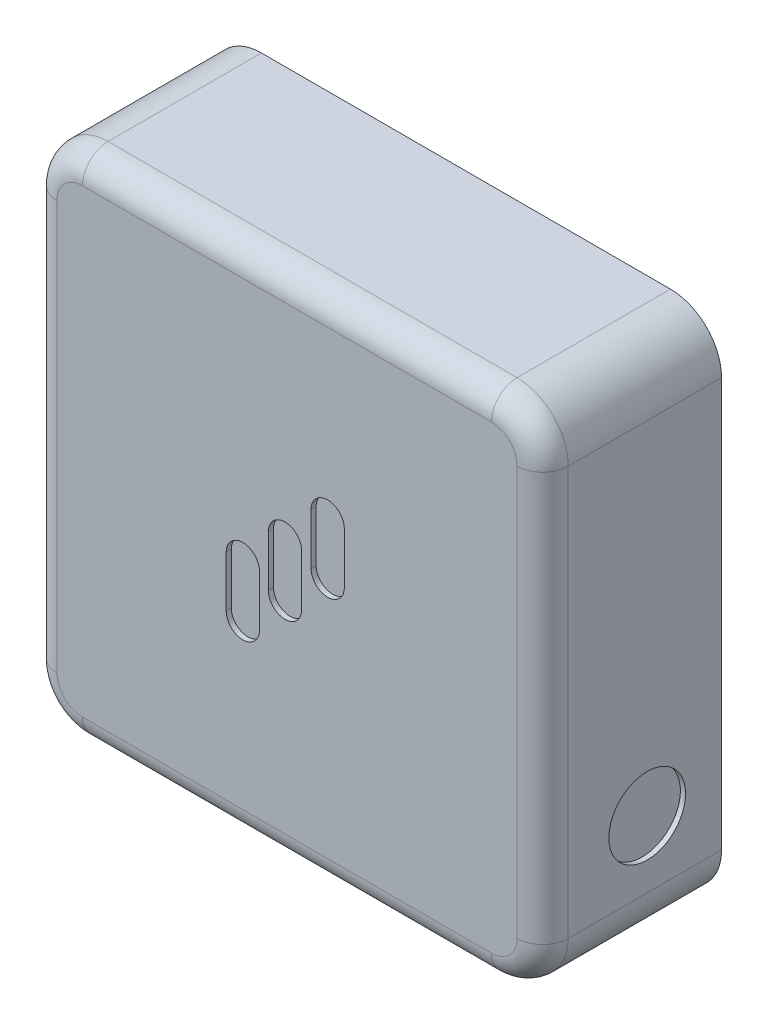
from build123d import *

# Parameters (mm, degrees)
SKETCH1_W           = 100
SKETCH1_H           = 100
BOSS_EXTRUDE2_DEPTH = 35
FILLET3_R           = 10
FILLET4_R           = 5
SKETCH2_R           = 7.5
CUT_EXTRUDE1_DEPTH  = 1
CUT_EXTRUDE2_DEPTH  = 1


with BuildPart() as part:
    # Sketch1 → Boss-Extrude2 (new body)
    with BuildSketch(Plane.XY):
        with Locations((-7.378614961, -23.844584937)):
            Rectangle(SKETCH1_W, SKETCH1_H)
    extrude(amount=BOSS_EXTRUDE2_DEPTH)

    # Fillet3
    fillet3_edges = [part.edges().sort_by_distance(p)[0] for p in [
        (-57.378614961, 26.155415063, 17.5),
        (42.621385039, 26.155415063, 17.5),
        (42.621385039, -73.844584937, 17.5),
        (-57.378614961, -73.844584937, 17.5),
    ]]
    fillet(fillet3_edges, radius=FILLET3_R)

    # Fillet4
    fillet4_edges = [part.edges().sort_by_distance(p)[0] for p in [
        (42.621385039, -23.844584937, 35),
        (-7.378614961, -73.844584937, 35),
        (-57.378614961, -23.844584937, 35),
        (-7.378614961, 26.155415063, 35),
        (39.692452851, 23.226482875, 35),
        (-54.449682772, 23.226482875, 35),
        (-54.449682772, -70.915652749, 35),
        (39.692452851, -70.915652749, 35),
    ]]
    fillet(fillet4_edges, radius=FILLET4_R)

    # Sketch2 → Cut-Extrude1 (cut)
    with BuildSketch(Plane(origin=(42.621385039, 0, 0), x_dir=(0, 0, -1), z_dir=(1, 0, 0))):
        with Locations((-14.550369157, -50.784546634)):
            Circle(SKETCH2_R)
    extrude(amount=-CUT_EXTRUDE1_DEPTH, mode=Mode.SUBTRACT)

    # Sketch3 → Cut-Extrude2 (cut)
    with BuildSketch(Plane.XY.offset(35)):
        with BuildLine():
            Line((-19.273762165, -36.822061823), (-19.273762165, -26.851128879))
            ThreePointArc((-19.273762165, -26.851128879), (-16.017889756, -23.595256471), (-12.762017347, -26.851128879))
            Line((-12.762017347, -26.851128879), (-12.762017347, -36.822061823))
            ThreePointArc((-12.762017347, -36.822061823), (-16.017889756, -40.077934232), (-19.273762165, -36.822061823))
        make_face()
        with BuildLine():
            Line((-11.027771482, -29.224294891), (-11.027771482, -19.253361947))
            ThreePointArc((-11.027771482, -19.253361947), (-7.771899073, -15.997489538), (-4.516026664, -19.253361947))
            Line((-4.516026664, -19.253361947), (-4.516026664, -29.224294891))
            ThreePointArc((-4.516026664, -29.224294891), (-7.771899073, -32.4801673), (-11.027771482, -29.224294891))
        make_face()
        with BuildLine():
            Line((-2.681741214, -21.311514936), (-2.681741214, -11.340581993))
            ThreePointArc((-2.681741214, -11.340581993), (0.574131194, -8.084709584), (3.830003603, -11.340581993))
            Line((3.830003603, -11.340581993), (3.830003603, -21.311514936))
            ThreePointArc((3.830003603, -21.311514936), (0.574131194, -24.567387345), (-2.681741214, -21.311514936))
        make_face()
    extrude(amount=-CUT_EXTRUDE2_DEPTH, mode=Mode.SUBTRACT)


solid = part.part
